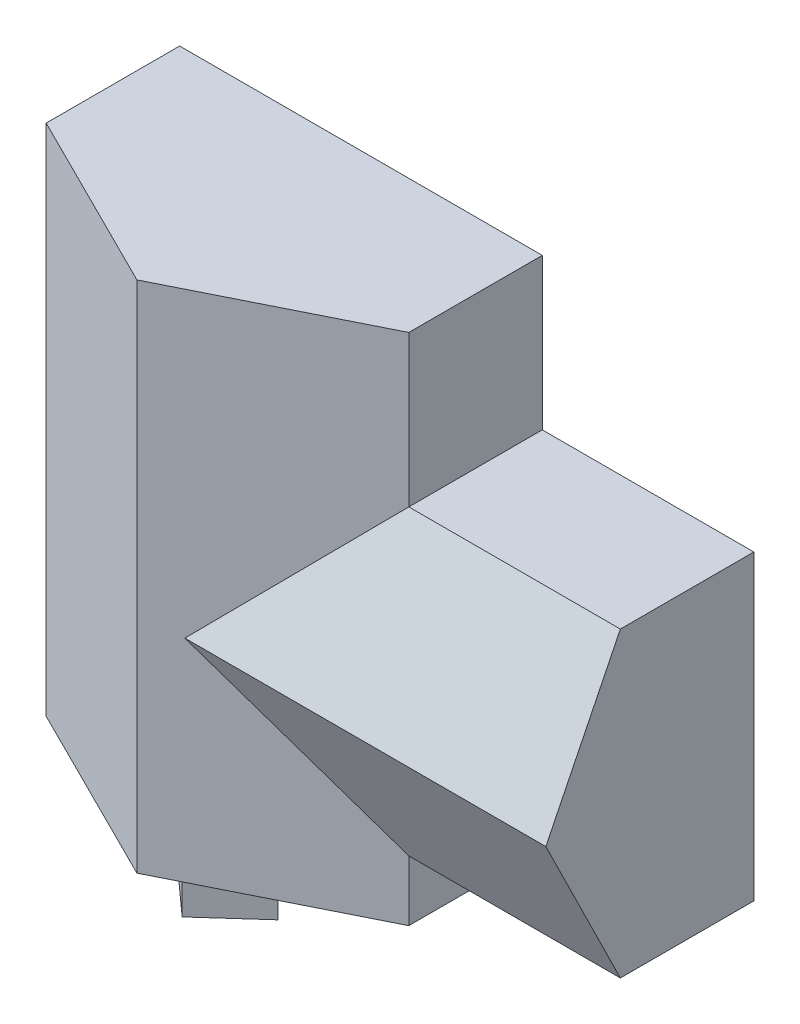
from build123d import *

# Parameters (mm, degrees)
SKETCH3_W            = 11582.4
SKETCH3_H            = 6096
SKETCH3_W_2          = 4341.154286856
SKETCH3_H_2          = 914.4
SKETCH3_W_3          = 1676.4
SKETCH3_H_3          = 2330.801356814
SKETCH3_W_4          = 2663.595025017
SKETCH3_H_4          = 2342.798643186
SKETCH3_W_5          = 1043.645713144
SKETCH3_W_6          = 4013.2
SKETCH3_W_7          = 3708.4
BOSS_EXTRUDE1_DEPTH  = 2438.4
SKETCH4_W            = 11582.4
SKETCH4_H            = 6096
BOSS_EXTRUDE2_DEPTH  = 254
SKETCH5_W            = 3178.404974983
SKETCH5_H            = 101.6
BOSS_EXTRUDE3_DEPTH  = 1016
BOSS_EXTRUDE4_DEPTH  = 11582.4
SKETCH8_W            = 7315.2
SKETCH8_H            = 3048
BOSS_EXTRUDE6_DEPTH  = 254
BOSS_EXTRUDE7_DEPTH  = 10363.2
SKETCH12_W           = 7315.2
SKETCH12_H           = 1219.2
BOSS_EXTRUDE8_DEPTH  = 2692.4
BOSS_EXTRUDE9_DEPTH  = 1219.2
SKETCH18_W           = 5091.335525139
SKETCH18_H           = 6725.356075379
CUT_EXTRUDE5_DEPTH   = 7574.28
SKETCH20_W           = 7315.2
SKETCH20_H           = 2438.4
BOSS_EXTRUDE10_DEPTH = 3048


with BuildPart() as part:
    # Sketch3 → Boss-Extrude1 (new body)
    with BuildSketch(Plane.XY):
        with Locations((5791.2, 3048)):
            Rectangle(SKETCH3_W, SKETCH3_H)
        Polygon((152.4, 152.4), (4550.004974983, 152.4), (4550.004974983, 2596.798643186), (5842, 2596.798643186), (5842, 3511.198643186), (5842, 5943.6), (152.4, 5943.6), align=None, mode=Mode.SUBTRACT)
        with Locations((8114.177143428, 3053.998643186)):
            Rectangle(SKETCH3_W_2, SKETCH3_H_2, mode=Mode.SUBTRACT)
        with Locations((6781.8, 4778.199321593)):
            Rectangle(SKETCH3_W_3, SKETCH3_H_3, mode=Mode.SUBTRACT)
        with Locations((5983.402487492, 1323.799321593)):
            Rectangle(SKETCH3_W_4, SKETCH3_H_4, mode=Mode.SUBTRACT)
        with Locations((10908.177143428, 3053.998643186)):
            Rectangle(SKETCH3_W_5, SKETCH3_H_2, mode=Mode.SUBTRACT)
        with Locations((9423.4, 1323.799321593)):
            Rectangle(SKETCH3_W_6, SKETCH3_H_4, mode=Mode.SUBTRACT)
        with Locations((9575.8, 4778.199321593)):
            Rectangle(SKETCH3_W_7, SKETCH3_H_3, mode=Mode.SUBTRACT)
    extrude(amount=BOSS_EXTRUDE1_DEPTH)

    # Sketch4 → Boss-Extrude2 (add)
    with BuildSketch(Plane(origin=(0, 0, 0), x_dir=(-1, 0, 0), z_dir=(0, 0, -1))):
        with Locations((-5791.2, 3048)):
            Rectangle(SKETCH4_W, SKETCH4_H)
    extrude(amount=BOSS_EXTRUDE2_DEPTH)

    # Sketch5 → Boss-Extrude3 (add)
    with BuildSketch(Plane.XY):
        with Locations((1741.602487492, 2545.998643186)):
            Rectangle(SKETCH5_W, SKETCH5_H)
    extrude(amount=BOSS_EXTRUDE3_DEPTH)

    # Sketch6 → Boss-Extrude4 (add)
    with BuildSketch(Plane.ZY):
        Polygon((2438.4, 6096), (2438.4, 0), (3941.507258543, 3048), align=None)
    extrude(amount=-BOSS_EXTRUDE4_DEPTH)

    # Sketch10 → Boss-Extrude7 (add)
    with BuildSketch(Plane(origin=(0, 9144, 0), x_dir=(1, 0, 0), z_dir=(0, 1, 0))):
        Polygon((7315.2, -2438.4), (0, -2438.4), (3655.110432816, -4263.253342026), align=None)
    extrude(amount=-BOSS_EXTRUDE7_DEPTH)

    # Sketch12 → Boss-Extrude8 (add)
    with BuildSketch(Plane(origin=(0, 0, -254), x_dir=(-1, 0, 0), z_dir=(0, 0, -1))):
        with Locations((-3657.6, -609.6)):
            Rectangle(SKETCH12_W, SKETCH12_H)
    extrude(amount=-BOSS_EXTRUDE8_DEPTH)

    # Sketch15 → Boss-Extrude9 (add)
    with BuildSketch(Plane.XZ.offset(1219.2)):
        Polygon((2641.6, 2438.4), (4673.6, 2438.4), (3657.6, 3352.8), align=None)
    extrude(amount=BOSS_EXTRUDE9_DEPTH)

    # Sketch18 → Cut-Extrude5 (cut)
    with BuildSketch(Plane(origin=(-974.493873117, 0, 1951.873413778), x_dir=(0.894691579, 0, 0.446684429), z_dir=(-0.446684429, 0, 0.894691579))):
        with Locations((2296.53232092, 2948.73787515)):
            Rectangle(SKETCH18_W, SKETCH18_H)
    extrude(amount=CUT_EXTRUDE5_DEPTH, mode=Mode.SUBTRACT)



with BuildPart() as body_2:
    # Sketch8 → Boss-Extrude6 (new body)
    with BuildSketch(Plane(origin=(0, 0, -254), x_dir=(-1, 0, 0), z_dir=(0, 0, -1))):
        with Locations((-3657.6, 7620)):
            Rectangle(SKETCH8_W, SKETCH8_H)
    extrude(amount=-BOSS_EXTRUDE6_DEPTH)


with BuildPart() as part_1:
    add(part.part)

    add(body_2.part)  # Boss-Extrude10 merges body 2
    # Sketch20 → Boss-Extrude10 (add)
    with BuildSketch(Plane(origin=(0, 6096, 0), x_dir=(1, 0, 0), z_dir=(0, 1, 0))):
        with Locations((3657.6, -1219.2)):
            Rectangle(SKETCH20_W, SKETCH20_H)
    extrude(amount=BOSS_EXTRUDE10_DEPTH)


solid = part_1.part
